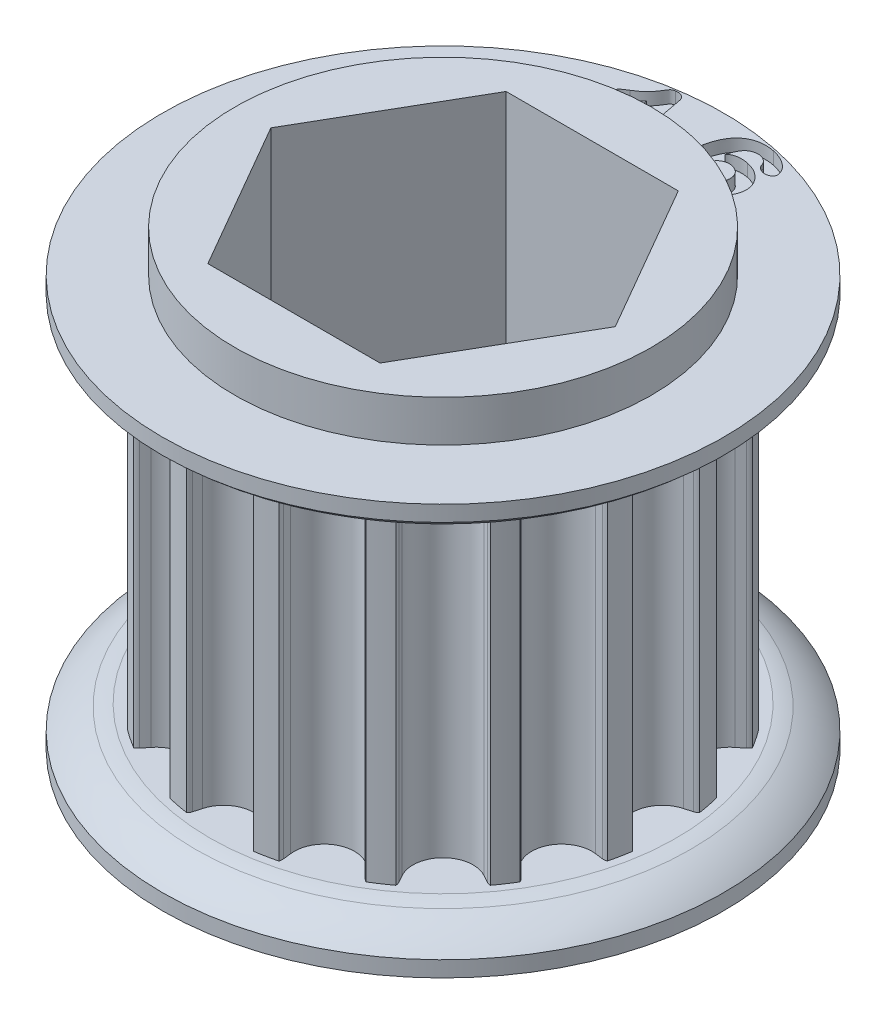
from build123d import *

# Parameters (mm, degrees)
SKETCH1_R                    = 7.258437513
TOOTHOD_DEPTH                = 5.334
TOOTHPROFILE_DEPTH           = 6.334
TOOTHPATTERN_COUNT           = 16
SKETCH6_W                    = 6.7056
SKETCH6_H                    = 1.3335
BORE_DEPTH                   = 8.9375
BORE_DEPTH_BACK              = 8.9375
SMALL_TOOTH_COUNT_DEPTH      = 2.3335
SMALL_TOOTH_COUNT_DEPTH_BACK = 0.4


with BuildPart() as part:
    # Sketch1 → ToothOD (new body, symmetric)
    with BuildSketch(Plane(origin=(0, 0, 0), x_dir=(1, 0, 0), z_dir=(0, 1, 0))):
        Circle(SKETCH1_R)
    extrude(amount=TOOTHOD_DEPTH, both=True)

    # Sketch2 → ToothProfile (cut, symmetric)
    with BuildSketch(Plane(origin=(0, 0, 0), x_dir=(1, 0, 0), z_dir=(0, 1, 0))):
        with BuildLine():
            ThreePointArc((-0.937033068, 6.808499509), (-0.590385173, 6.290324899), (0, 6.090037513))
            ThreePointArc((0, 6.090037513), (0.590385173, 6.290324899), (0.937033068, 6.808499509))
            ThreePointArc((0.937033068, 6.808499509), (0.971699064, 6.934610971), (1.007805813, 7.060317513))
            ThreePointArc((1.007805813, 7.060317513), (1.034366489, 7.123214994), (1.074472706, 7.178469442))
            ThreePointArc((1.074472706, 7.178469442), (0, 7.258437513), (-1.074472706, 7.178469442))
            ThreePointArc((-1.074472706, 7.178469442), (-1.034366489, 7.123214994), (-1.007805813, 7.060317513))
            ThreePointArc((-1.007805813, 7.060317513), (-0.971699064, 6.934610971), (-0.937033068, 6.808499509))
        make_face()
    toothprofile = extrude(amount=TOOTHPROFILE_DEPTH, both=True, mode=Mode.SUBTRACT)

    # ToothPattern: ToothProfile ×16 about axis
    toothpattern_axis = Axis((0, 0, 0), (0, 1, 0))
    for i in range(1, TOOTHPATTERN_COUNT):
        add(toothprofile.rotate(toothpattern_axis, i * 360 / TOOTHPATTERN_COUNT), mode=Mode.SUBTRACT)

    # Sketch4 → Flange (revolve)
    with BuildSketch(Plane.XY):
        with BuildLine():
            Line((0, -5.334), (7.512437513, -5.334))
            ThreePointArc((7.512437513, -5.334), (7.742084134, -5.369951298), (7.967509841, -5.426637424))
            ThreePointArc((7.967509841, -5.426637424), (8.535238418, -5.708197125), (9.036437513, -6.096))
            Line((9.036437513, -6.096), (9.036437513, -6.604))
            Line((9.036437513, -6.604), (0, -6.604))
            Line((0, -6.604), (0, -5.334))
        make_face()
        with BuildLine():
            Line((9.036437513, 6.604), (9.036437513, 6.096))
            ThreePointArc((9.036437513, 6.096), (8.535238418, 5.708197125), (7.967509841, 5.426637424))
            ThreePointArc((7.967509841, 5.426637424), (7.742084134, 5.369951298), (7.512437513, 5.334))
            Line((7.512437513, 5.334), (0, 5.334))
            Line((0, 5.334), (0, 6.604))
            Line((0, 6.604), (9.036437513, 6.604))
        make_face()
    revolve(axis=Axis((0, 8.73125, 0), (0, -1, 0)))

    # Sketch6 → TopBearingBoss (revolve)
    with BuildSketch(Plane.XY):
        with Locations((3.3528, 7.27075)):
            Rectangle(SKETCH6_W, SKETCH6_H)
    topbearingboss = revolve(axis=Axis((0, 8.73125, 0), (0, -1, 0)))

    # BottomBearingBoss: TopBearingBoss across plane
    add(topbearingboss.mirror(Plane.ZX))

    # Sketch7 → Bore (cut, two sides)
    with BuildSketch(Plane.XZ) as bore_sk:
        Polygon((2.771627702, 4.8006), (-2.771627702, 4.8006), (-5.543255405, 0), (-2.771627702, -4.8006), (2.771627702, -4.8006), (5.543255405, 0), align=None)
    extrude(amount=BORE_DEPTH, mode=Mode.SUBTRACT)
    extrude(bore_sk.sketch, amount=-BORE_DEPTH_BACK, mode=Mode.SUBTRACT)

    # Sketch11 → Small Tooth Count (cut, two sides)
    with BuildSketch(Plane(origin=(0, 6.604, 0), x_dir=(1, 0, 0), z_dir=(0, 1, 0))) as small_tooth_count_sk:
        with BuildLine():
            Line((-1.338134522, 6.847510252), (-1.580129053, 8.128920409))
            add(Edge.make_bspline(
                [(-1.580129053, 8.128920409), (-1.609297786, 8.100189025), (-1.665029372, 8.045293066), (-1.746954619, 7.969358236), (-1.823360473, 7.903564051), (-1.894836107, 7.848764993), (-1.960093837, 7.803072097), (-2.020225003, 7.768377529), (-2.074704659, 7.742859019), (-2.110539085, 7.733897878), (-2.127072413, 7.729763377)],
                knots=[0, 0, 0, 0, 0.000122822, 0.000234672, 0.000335063, 0.00042517, 0.000504802, 0.000573805, 0.000633374, 0.0006844, 0.0006844, 0.0006844, 0.0006844], degree=3))
            add(Edge.make_bspline(
                [(-2.127072413, 7.729763377), (-2.141631076, 7.727716758), (-2.170267885, 7.723691071), (-2.213522842, 7.727359943), (-2.255569865, 7.737557312), (-2.295259046, 7.755373546), (-2.330737307, 7.778824168), (-2.359143871, 7.807746022), (-2.379392503, 7.841485999), (-2.385874963, 7.866312804), (-2.389158741, 7.878889159)],
                knots=[0, 0, 0, 0, 4.3983e-05, 8.6514e-05, 0.000129288, 0.000173261, 0.000216356, 0.00025614, 0.000293968, 0.000332802, 0.000332802, 0.000332802, 0.000332802], degree=3))
            add(Edge.make_bspline(
                [(-2.389158741, 7.878889159), (-2.391260924, 7.893305698), (-2.39524001, 7.920593833), (-2.389166991, 7.960178849), (-2.374099132, 7.995181689), (-2.34711947, 8.024798766), (-2.310570785, 8.052663137), (-2.265338804, 8.084846744), (-2.209900555, 8.121504487), (-2.168843209, 8.146342707), (-2.146717725, 8.15972783)],
                knots=[0, 0, 0, 0, 4.3495e-05, 8.2329e-05, 0.000118505, 0.000156182, 0.000200949, 0.000256329, 0.000322704, 0.000400275, 0.000400275, 0.000400275, 0.000400275], degree=3))
            add(Edge.make_bspline(
                [(-2.146717725, 8.15972783), (-2.114507435, 8.179945961), (-2.052911108, 8.218609462), (-1.968009579, 8.279026604), (-1.893730417, 8.33751395), (-1.830651049, 8.396866843), (-1.774946823, 8.456373861), (-1.723727089, 8.517163284), (-1.677087741, 8.580709334), (-1.641136897, 8.634656765), (-1.61509848, 8.67729256), (-1.596897821, 8.706235736), (-1.579943899, 8.732046946), (-1.56459731, 8.754855124), (-1.551424316, 8.775051155), (-1.539348812, 8.791909955), (-1.528965572, 8.805926547), (-1.517096453, 8.821381251), (-1.498340748, 8.837934453), (-1.468773352, 8.852841896), (-1.431368635, 8.865877555), (-1.403415375, 8.87177386), (-1.388140772, 8.874995799)],
                knots=[0, 0, 0, 0, 0.000114067, 0.000218132, 0.000312476, 0.00039745, 0.000477681, 0.000556914, 0.000635765, 0.000714027, 0.000751321, 0.000785633, 0.000816593, 0.00084396, 0.000868107, 0.00088892, 0.000906154, 0.000920449, 0.000947331, 0.000980292, 0.001019126, 0.001065911, 0.001065911, 0.001065911, 0.001065911], degree=3))
            add(Edge.make_bspline(
                [(-1.388140772, 8.874995799), (-1.36721257, 8.878110771), (-1.327378659, 8.884039686), (-1.26894861, 8.881084964), (-1.215898868, 8.867224091), (-1.169265312, 8.842645747), (-1.129143922, 8.810714261), (-1.097912146, 8.771232752), (-1.074134372, 8.726184854), (-1.066252714, 8.692931969), (-1.062207178, 8.675863768)],
                knots=[0, 0, 0, 0, 6.3358e-05, 0.000120594, 0.000174203, 0.000226524, 0.000277636, 0.000326865, 0.000376588, 0.000429024, 0.000429024, 0.000429024, 0.000429024], degree=3))
            Line((-1.062207178, 8.675863768), (-0.748775147, 7.018067284))
            add(Edge.make_bspline(
                [(-0.748775147, 7.018067284), (-0.746489232, 7.005148637), (-0.742042556, 6.980018648), (-0.738914334, 6.94296791), (-0.738977572, 6.907888493), (-0.741377483, 6.874814187), (-0.747292618, 6.843876617), (-0.75573094, 6.814916317), (-0.767276155, 6.787969326), (-0.782334544, 6.763311318), (-0.799648894, 6.740216272), (-0.820575886, 6.719766035), (-0.843805582, 6.700693111), (-0.870455113, 6.68440776), (-0.899580025, 6.669437914), (-0.931939574, 6.657031443), (-0.967249109, 6.646864149), (-0.991922899, 6.641671976), (-1.004610694, 6.639002049)],
                knots=[0, 0, 0, 0, 3.9344e-05, 7.6534e-05, 0.000111359, 0.000144508, 0.000175857, 0.000205665, 0.000234861, 0.000263499, 0.000292164, 0.00032121, 0.000351054, 0.000382148, 0.000414696, 0.000449188, 0.000485924, 0.000524812, 0.000524812, 0.000524812, 0.000524812], degree=3))
            add(Edge.make_bspline(
                [(-1.004610694, 6.639002049), (-1.024943979, 6.635956693), (-1.063866326, 6.630127217), (-1.121533846, 6.63227239), (-1.174610091, 6.644428989), (-1.223321085, 6.66529961), (-1.265621062, 6.696420058), (-1.299498125, 6.738029738), (-1.324316948, 6.789340212), (-1.333376143, 6.827478145), (-1.338134522, 6.847510252)],
                knots=[0, 0, 0, 0, 6.1584e-05, 0.000117885, 0.000171932, 0.000224112, 0.000275815, 0.000327838, 0.000383548, 0.000445186, 0.000445186, 0.000445186, 0.000445186], degree=3))
        make_face()
        with BuildLine():
            add(Edge.make_bspline(
                [(1.176913204, 7.894845341), (1.1835711, 7.90349143), (1.196913519, 7.920818188), (1.220462258, 7.943996518), (1.246397367, 7.9652838), (1.275504636, 7.983401405), (1.30729912, 7.999130122), (1.341413066, 8.012927915), (1.37844537, 8.024223949), (1.431739846, 8.035177018), (1.501779437, 8.044001309), (1.588818058, 8.046923646), (1.678826848, 8.039934848), (1.739111586, 8.029300609), (1.769844454, 8.023879326)],
                knots=[0, 0, 0, 0, 3.2703e-05, 6.5537e-05, 9.8869e-05, 0.000133181, 0.000168124, 0.000205185, 0.00024346, 0.000284093, 0.00036827, 0.00045493, 0.000544923, 0.000638512, 0.000638512, 0.000638512, 0.000638512], degree=3))
            add(Edge.make_bspline(
                [(1.769844454, 8.023879326), (1.800460843, 8.016863813), (1.860810704, 8.003035102), (1.948112572, 7.975277413), (2.029695683, 7.939295964), (2.106669621, 7.898690128), (2.177521464, 7.851438424), (2.24314745, 7.800345881), (2.301973322, 7.743673095), (2.354064815, 7.682491422), (2.399588536, 7.618284105), (2.437157407, 7.550917222), (2.466616513, 7.481297341), (2.48822618, 7.409584455), (2.501338253, 7.337064165), (2.507560247, 7.264526604), (2.504936767, 7.192261781), (2.497082673, 7.14483864), (2.493149141, 7.121087919)],
                knots=[0, 0, 0, 0, 9.4212e-05, 0.000185708, 0.000274293, 0.000361384, 0.000446458, 0.000529438, 0.000610591, 0.00069103, 0.000770184, 0.000846335, 0.000921964, 0.000996547, 0.001070546, 0.001142664, 0.001214598, 0.00128677, 0.00128677, 0.00128677, 0.00128677], degree=3))
            add(Edge.make_bspline(
                [(2.493149141, 7.121087919), (2.489256533, 7.104047005), (2.481525936, 7.070204289), (2.465097752, 7.02088577), (2.445690162, 6.973150566), (2.422211734, 6.927412002), (2.395470588, 6.883324977), (2.364245693, 6.841563802), (2.330606425, 6.800551888), (2.292415055, 6.762442004), (2.251587247, 6.72626994), (2.207689381, 6.693137858), (2.160983275, 6.663263633), (2.11180249, 6.635730023), (2.05948063, 6.61199413), (2.004795195, 6.590207007), (1.947154191, 6.572059211), (1.887043049, 6.557017847), (1.825069073, 6.5448901), (1.761551677, 6.536447224), (1.69685549, 6.531555849), (1.630829046, 6.530263612), (1.563752545, 6.532431813), (1.495417728, 6.538593318), (1.425864833, 6.547025262), (1.379420978, 6.556142961), (1.355953438, 6.560750029)],
                knots=[0, 0, 0, 0, 5.2412e-05, 0.000104089, 0.000155744, 0.000206862, 0.000258167, 0.00031023, 0.000363166, 0.000417154, 0.000471882, 0.000526711, 0.000581947, 0.000638106, 0.00069564, 0.000754176, 0.000814612, 0.000876769, 0.00093999, 0.001003956, 0.001068882, 0.001134529, 0.001201985, 0.001270099, 0.00134032, 0.001412043, 0.001412043, 0.001412043, 0.001412043], degree=3))
            add(Edge.make_bspline(
                [(1.355953438, 6.560750029), (1.330129346, 6.566240828), (1.279322552, 6.577043527), (1.205655895, 6.598359405), (1.135289877, 6.622214456), (1.068632138, 6.65015006), (1.005169684, 6.680807069), (0.945199781, 6.71479464), (0.888606611, 6.752002576), (0.835560254, 6.792493481), (0.786253116, 6.836328758), (0.74119983, 6.883345777), (0.69976437, 6.932905145), (0.663257614, 6.985876161), (0.630405674, 7.041448047), (0.601840191, 7.10015732), (0.577223825, 7.16174541), (0.557181414, 7.226441548), (0.541161619, 7.293697257), (0.529402309, 7.363489485), (0.523026101, 7.435883289), (0.520240116, 7.510703276), (0.522129979, 7.588077416), (0.528521048, 7.667794686), (0.539137598, 7.750076996), (0.549617348, 7.80544665), (0.55496047, 7.833676982)],
                knots=[0, 0, 0, 0, 7.918e-05, 0.000155781, 0.000229909, 0.000301965, 0.000372454, 0.000441236, 0.000508602, 0.000575488, 0.000641265, 0.000706314, 0.000770684, 0.000834841, 0.000899087, 0.000964183, 0.001030512, 0.001097871, 0.00116718, 0.001237793, 0.001309988, 0.001385045, 0.001462307, 0.001542027, 0.001624876, 0.001711056, 0.001711056, 0.001711056, 0.001711056], degree=3))
            add(Edge.make_bspline(
                [(0.55496047, 7.833676982), (0.564934885, 7.878818743), (0.584388852, 7.966862633), (0.625287114, 8.092594709), (0.672163827, 8.209872624), (0.727555675, 8.317355708), (0.789446447, 8.4153046), (0.858373345, 8.502052402), (0.932905829, 8.578621477), (1.014170879, 8.643640478), (1.101371144, 8.697901246), (1.193839098, 8.742079994), (1.291941255, 8.775062296), (1.395194192, 8.798009651), (1.503573314, 8.809654199), (1.616572337, 8.811513099), (1.734187093, 8.801939813), (1.813249479, 8.787879065), (1.853783516, 8.780670341)],
                knots=[0, 0, 0, 0, 0.000138617, 0.000270358, 0.000396134, 0.000517144, 0.00063258, 0.000743171, 0.000848939, 0.000952487, 0.001054572, 0.001156425, 0.001259214, 0.001364399, 0.001473119, 0.001585647, 0.001703001, 0.001826464, 0.001826464, 0.001826464, 0.001826464], degree=3))
            add(Edge.make_bspline(
                [(1.853783516, 8.780670341), (1.894018451, 8.771582115), (1.972289215, 8.753902395), (2.083646188, 8.715779668), (2.186600003, 8.670669332), (2.279232868, 8.616565208), (2.361312015, 8.558411801), (2.431361625, 8.497383772), (2.48894701, 8.434622729), (2.532141099, 8.369632773), (2.563567791, 8.306444985), (2.583992826, 8.246663246), (2.592982422, 8.190064746), (2.588577175, 8.154394263), (2.586464376, 8.137286357)],
                knots=[0, 0, 0, 0, 0.000123667, 0.000240574, 0.000352503, 0.000460328, 0.000561798, 0.000653866, 0.000738592, 0.000816483, 0.000887169, 0.000949716, 0.001005598, 0.001057101, 0.001057101, 0.001057101, 0.001057101], degree=3))
            add(Edge.make_bspline(
                [(2.586464376, 8.137286357), (2.58345982, 8.126905077), (2.577253507, 8.105461147), (2.556042386, 8.076950251), (2.527179523, 8.050824426), (2.490672674, 8.027622792), (2.447446456, 8.009719281), (2.398999641, 7.999877029), (2.346077381, 7.999189078), (2.310178404, 8.005132956), (2.291338204, 8.008252373)],
                knots=[0, 0, 0, 0, 3.2196e-05, 6.6506e-05, 0.00010474, 0.000148709, 0.000195556, 0.000244329, 0.000296129, 0.000353338, 0.000353338, 0.000353338, 0.000353338], degree=3))
            add(Edge.make_bspline(
                [(2.291338204, 8.008252373), (2.277700114, 8.011498309), (2.250660812, 8.017933804), (2.211865553, 8.033317571), (2.175720081, 8.053720971), (2.141753004, 8.077462405), (2.111970685, 8.105307346), (2.087423725, 8.136615865), (2.068349492, 8.170694483), (2.060136581, 8.195175918), (2.056040938, 8.207384404)],
                knots=[0, 0, 0, 0, 4.2019e-05, 8.3309e-05, 0.00012468, 0.000166307, 0.000207369, 0.000246489, 0.000285259, 0.000323825, 0.000323825, 0.000323825, 0.000323825], degree=3))
            add(Edge.make_bspline(
                [(2.056040938, 8.207384404), (2.051578565, 8.220967478), (2.042572011, 8.248382635), (2.020509569, 8.286608052), (1.991888582, 8.322235938), (1.957077836, 8.354970542), (1.91694277, 8.384564718), (1.871445974, 8.409180329), (1.821158563, 8.428579951), (1.785449173, 8.436725246), (1.767165548, 8.440895732)],
                knots=[0, 0, 0, 0, 4.28e-05, 8.6384e-05, 0.000131499, 0.000179504, 0.000229334, 0.000280682, 0.000334247, 0.000390449, 0.000390449, 0.000390449, 0.000390449], degree=3))
            add(Edge.make_bspline(
                [(1.767165548, 8.440895732), (1.753657394, 8.443137056), (1.726328968, 8.447671493), (1.684039544, 8.448844842), (1.640390252, 8.4450263), (1.595692107, 8.437035373), (1.550370144, 8.424657847), (1.505725926, 8.406731351), (1.461912387, 8.383262439), (1.434352323, 8.364090095), (1.420247188, 8.354277763)],
                knots=[0, 0, 0, 0, 4.1043e-05, 8.3033e-05, 0.00012649, 0.000172295, 0.000219091, 0.000267179, 0.000316318, 0.000367833, 0.000367833, 0.000367833, 0.000367833], degree=3))
            add(Edge.make_bspline(
                [(1.420247188, 8.354277763), (1.407872788, 8.344194377), (1.382069264, 8.323168154), (1.348138026, 8.283352324), (1.314705502, 8.237170938), (1.283865388, 8.182892045), (1.254543868, 8.121440295), (1.226271125, 8.05281447), (1.200128752, 7.976562296), (1.184841928, 7.922753843), (1.176913204, 7.894845341)],
                knots=[0, 0, 0, 0, 4.7799e-05, 9.9672e-05, 0.000156298, 0.000218712, 0.000286608, 0.000360485, 0.00044125, 0.000528279, 0.000528279, 0.000528279, 0.000528279], degree=3))
        make_face()
        with BuildLine():
            add(Edge.make_bspline(
                [(1.434088204, 6.901864091), (1.448486275, 6.899209332), (1.476689208, 6.89400919), (1.518871256, 6.890987485), (1.55970034, 6.891736008), (1.599306336, 6.896797887), (1.637710554, 6.905289019), (1.6751973, 6.917145695), (1.710938315, 6.934168683), (1.745723107, 6.953910443), (1.778081447, 6.977568123), (1.80789075, 7.004006642), (1.834371818, 7.033694181), (1.857598583, 7.066411109), (1.877761093, 7.102086943), (1.89534463, 7.140491467), (1.909112417, 7.182179476), (1.915642515, 7.211215215), (1.918970235, 7.226011748)],
                knots=[0, 0, 0, 0, 4.3894e-05, 8.598e-05, 0.00012662, 0.000166216, 0.00020554, 0.000244509, 0.000283863, 0.000324069, 0.000364347, 0.000403873, 0.000443399, 0.000483416, 0.000524009, 0.000566171, 0.00060994, 0.000655422, 0.000655422, 0.000655422, 0.000655422], degree=3))
            add(Edge.make_bspline(
                [(1.918970235, 7.226011748), (1.922461516, 7.246041339), (1.92922821, 7.284862073), (1.93064322, 7.342749817), (1.923953536, 7.397462234), (1.909916489, 7.448963323), (1.88948859, 7.496863739), (1.86229125, 7.54072581), (1.829035448, 7.580259855), (1.789852313, 7.615062317), (1.74621626, 7.645337371), (1.698718937, 7.67039794), (1.647607129, 7.690044134), (1.611765167, 7.698233431), (1.593483126, 7.702410576)],
                knots=[0, 0, 0, 0, 6.0933e-05, 0.000118099, 0.00017298, 0.000225728, 0.000277729, 0.000328654, 0.00037999, 0.00043216, 0.000485417, 0.000538943, 0.000592925, 0.000649127, 0.000649127, 0.000649127, 0.000649127], degree=3))
            add(Edge.make_bspline(
                [(1.593483126, 7.702410576), (1.57745335, 7.705168335), (1.545409271, 7.710681191), (1.496533063, 7.712180616), (1.44744794, 7.708605457), (1.398640739, 7.699678616), (1.350739486, 7.685703234), (1.305283236, 7.665041766), (1.262886699, 7.637640634), (1.223282529, 7.604989435), (1.187887935, 7.5660701), (1.159705724, 7.520060398), (1.137517625, 7.468291786), (1.128450498, 7.430968249), (1.123781563, 7.411749248)],
                knots=[0, 0, 0, 0, 4.8747e-05, 9.7446e-05, 0.000146244, 0.000196162, 0.000246027, 0.000295579, 0.000345369, 0.000397048, 0.000449218, 0.000502366, 0.000558178, 0.000617426, 0.000617426, 0.000617426, 0.000617426], degree=3))
            add(Edge.make_bspline(
                [(1.123781563, 7.411749248), (1.1210279, 7.396006076), (1.115622202, 7.36510076), (1.111476266, 7.319122582), (1.111749885, 7.274673441), (1.116980073, 7.23198498), (1.125164782, 7.190573851), (1.138283533, 7.150813173), (1.155303061, 7.112645954), (1.176313619, 7.076454829), (1.200723409, 7.043091702), (1.227028171, 7.012153506), (1.256374485, 6.985595872), (1.287199012, 6.961373863), (1.3209274, 6.941595404), (1.356431162, 6.924235528), (1.394369273, 6.910863231), (1.42077401, 6.904880695), (1.434088204, 6.901864091)],
                knots=[0, 0, 0, 0, 4.7932e-05, 9.4095e-05, 0.000138299, 0.000180999, 0.000222942, 0.000264736, 0.000306307, 0.000348119, 0.000390006, 0.000430202, 0.000469697, 0.000508544, 0.000547595, 0.000586736, 0.000626981, 0.000667915, 0.000667915, 0.000667915, 0.000667915], degree=3))
        make_face(mode=Mode.SUBTRACT)
    extrude(amount=SMALL_TOOTH_COUNT_DEPTH, mode=Mode.SUBTRACT)
    extrude(small_tooth_count_sk.sketch, amount=-SMALL_TOOTH_COUNT_DEPTH_BACK, mode=Mode.SUBTRACT)


solid = part.part
